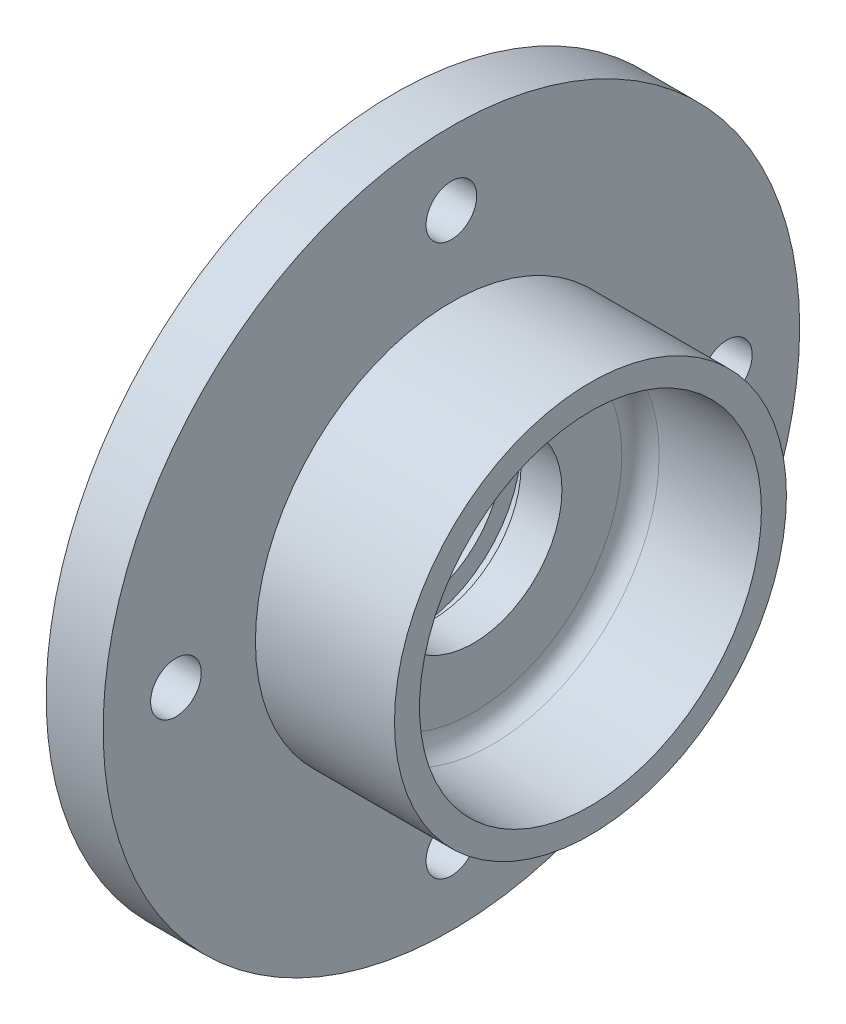
from build123d import *

# Parameters (mm, degrees)
SKETCH_1_R          = 55
EXTRUDE_1_DEPTH     = 9
SKETCH_2_R          = 30.95
EXTRUDE_2_DEPTH     = 21.96
SKETCH_3_R          = 27
CUT_EXTRUDE_1_DEPTH = 18.5
CUT_EXTRUDE_1_TAPER = 2
FILLET_1_R          = 3
SKETCH_4_R          = 14
CUT_EXTRUDE_2_DEPTH = 18.5
SKETCH_5_W          = 3
SKETCH_5_H          = 6
SKETCH_7_R          = 32
CUT_EXTRUDE_3_DEPTH = 1
CUT_EXTRUDE_4_DEPTH = 20


with BuildPart() as part:
    # 草图1 → 凸台-拉伸1 (new body)
    with BuildSketch(Plane(origin=(0, 0, 0), x_dir=(0, 0, -1), z_dir=(1, 0, 0))):
        Circle(SKETCH_1_R)
    extrude(amount=EXTRUDE_1_DEPTH)

    # 草图2 → 凸台-拉伸2 (add)
    with BuildSketch(Plane(origin=(9, 0, 0), x_dir=(0, 0, -1), z_dir=(1, 0, 0))):
        Circle(SKETCH_2_R)
    extrude(amount=EXTRUDE_2_DEPTH)

    # 草图3 → 切除-拉伸1 (cut)
    with BuildSketch(Plane(origin=(30.96, 0, 0), x_dir=(0, 0, -1), z_dir=(1, 0, 0))):
        Circle(SKETCH_3_R)
    extrude(amount=-CUT_EXTRUDE_1_DEPTH, taper=CUT_EXTRUDE_1_TAPER, mode=Mode.SUBTRACT)

    # 圆角1
    fillet_1_edges = [part.edges().sort_by_distance(p)[0] for p in [
        (12.46, 0, 26.353965764),
    ]]
    fillet(fillet_1_edges, radius=FILLET_1_R)

    # 草图4 → 切除-拉伸2 (cut)
    with BuildSketch(Plane(origin=(12.46, 0, 0), x_dir=(0, 0, -1), z_dir=(1, 0, 0))):
        Circle(SKETCH_4_R)
    extrude(amount=-CUT_EXTRUDE_2_DEPTH, mode=Mode.SUBTRACT)

    # 切除-扫描1: sweep along a path in 草图6
    with BuildLine(Plane(origin=(4.5, 0, 14), x_dir=(0, 0, -1), z_dir=(1, 0, 0))) as sweep_1_path:
        CenterArc((14, 0), 14, 0, 360)
    # 草图5 → 切除-扫描1 (sweep, cut)
    with BuildSketch(Plane(origin=(0, 0, 0), x_dir=(1, 0, 0), z_dir=(0, 1, 0))):
        with Locations((4.5, -14)):
            Rectangle(SKETCH_5_W, SKETCH_5_H)
    sweep(path=sweep_1_path.line, mode=Mode.SUBTRACT)

    # 草图7 → 切除-拉伸3 (cut)
    with BuildSketch(Plane.ZY):
        Circle(SKETCH_7_R)
    extrude(amount=-CUT_EXTRUDE_3_DEPTH, mode=Mode.SUBTRACT)

    # 草图8 → 切除-拉伸4 (cut)
    with BuildSketch(Plane.ZY):
        with BuildLine():
            ThreePointArc((0, 47.5), (-4, 43.5), (0, 39.5))
            Line((0, 39.5), (0, 47.5))
        make_face()
        with BuildLine():
            Line((0, 47.5), (0, 39.5))
            ThreePointArc((0, 39.5), (2.828427125, 40.671572875), (4, 43.5))
            ThreePointArc((4, 43.5), (2.828427125, 46.328427125), (0, 47.5))
        make_face()
        with BuildLine():
            ThreePointArc((47.5, 0), (43.5, 4), (39.5, 0))
            Line((39.5, 0), (47.5, 0))
        make_face()
        with BuildLine():
            Line((47.5, 0), (39.5, 0))
            ThreePointArc((39.5, 0), (43.5, -4), (47.5, 0))
        make_face()
        with BuildLine():
            ThreePointArc((0, -39.5), (-4, -43.5), (0, -47.5))
            Line((0, -47.5), (0, -39.5))
        make_face()
        with BuildLine():
            Line((0, -39.5), (0, -47.5))
            ThreePointArc((0, -47.5), (2.828427125, -46.328427125), (4, -43.5))
            ThreePointArc((4, -43.5), (2.828427125, -40.671572875), (0, -39.5))
        make_face()
        with BuildLine():
            ThreePointArc((-39.5, 0), (-43.5, 4), (-47.5, 0))
            Line((-47.5, 0), (-39.5, 0))
        make_face()
        with BuildLine():
            Line((-39.5, 0), (-47.5, 0))
            ThreePointArc((-47.5, 0), (-43.5, -4), (-39.5, 0))
        make_face()
    extrude(amount=-CUT_EXTRUDE_4_DEPTH, mode=Mode.SUBTRACT)


solid = part.part
